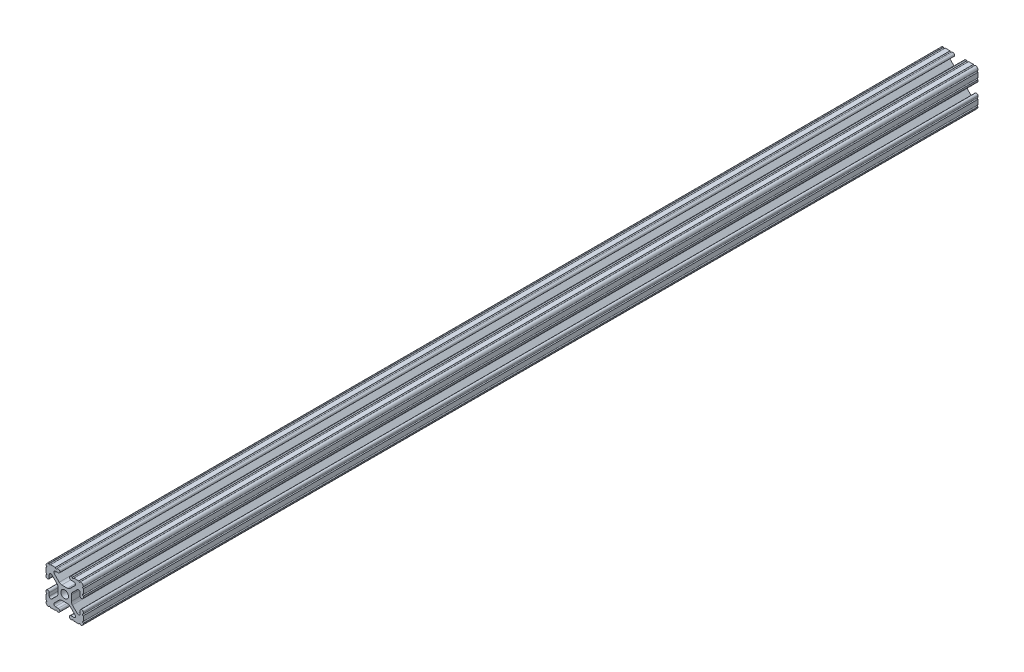
from build123d import *

# Parameters (mm, degrees)
SKETCH3_W                = 25.4
SKETCH3_H                = 25.4
BOSS_EXTRUDE1_DEPTH      = 304.8
BOSS_EXTRUDE1_DEPTH_BACK = 304.8
SKETCH4_R                = 2.6035
CUT_EXTRUDE1_DEPTH       = 610.6
CUT_EXTRUDE2_DEPTH       = 610.6
FILLET1_R                = 2.54
FILLET2_R                = 1.778


with BuildPart() as part:
    # Sketch3 → Boss-Extrude1 (new body, two sides)
    with BuildSketch(Plane.XY) as boss_extrude1_sk:
        Rectangle(SKETCH3_W, SKETCH3_H)
    extrude(amount=BOSS_EXTRUDE1_DEPTH)
    extrude(boss_extrude1_sk.sketch, amount=-BOSS_EXTRUDE1_DEPTH_BACK)

    # Sketch4 → Cut-Extrude1 (cut, through all)
    with BuildSketch(Plane.XY.offset(304.8)):
        with BuildLine():
            Line((3.2512, 12.7), (-3.2512, 12.7))
            Line((-3.2512, 12.7), (-3.2512, 10.4902))
            Line((-3.2512, 10.4902), (-6.348478019, 10.4902))
            ThreePointArc((-6.348478019, 10.4902), (-7.335478831, 9.830707141), (-7.103895736, 8.666460301))
            Line((-7.103895736, 8.666460301), (-2.958635435, 4.5212))
            Line((-2.958635435, 4.5212), (2.958635435, 4.5212))
            Line((2.958635435, 4.5212), (7.103895736, 8.666460301))
            ThreePointArc((7.103895736, 8.666460301), (7.335478831, 9.830707141), (6.348478019, 10.4902))
            Line((6.348478019, 10.4902), (3.2512, 10.4902))
            Line((3.2512, 10.4902), (3.2512, 12.7))
        make_face()
        with BuildLine():
            Line((12.7, -3.2512), (12.7, 3.2512))
            Line((12.7, 3.2512), (10.4902, 3.2512))
            Line((10.4902, 3.2512), (10.4902, 6.348478019))
            ThreePointArc((10.4902, 6.348478019), (9.830707141, 7.335478831), (8.666460301, 7.103895736))
            Line((8.666460301, 7.103895736), (4.5212, 2.958635435))
            Line((4.5212, 2.958635435), (4.5212, -2.958635435))
            Line((4.5212, -2.958635435), (8.666460301, -7.103895736))
            ThreePointArc((8.666460301, -7.103895736), (9.830707141, -7.335478831), (10.4902, -6.348478019))
            Line((10.4902, -6.348478019), (10.4902, -3.2512))
            Line((10.4902, -3.2512), (12.7, -3.2512))
        make_face()
        with BuildLine():
            Line((-3.2512, -10.4902), (-3.2512, -12.7))
            Line((-3.2512, -12.7), (3.2512, -12.7))
            Line((3.2512, -12.7), (3.2512, -10.4902))
            Line((3.2512, -10.4902), (6.348478019, -10.4902))
            ThreePointArc((6.348478019, -10.4902), (7.335478831, -9.830707141), (7.103895736, -8.666460301))
            Line((7.103895736, -8.666460301), (2.958635435, -4.5212))
            Line((2.958635435, -4.5212), (-2.958635435, -4.5212))
            Line((-2.958635435, -4.5212), (-7.103895736, -8.666460301))
            ThreePointArc((-7.103895736, -8.666460301), (-7.335478831, -9.830707141), (-6.348478019, -10.4902))
            Line((-6.348478019, -10.4902), (-3.2512, -10.4902))
        make_face()
        with BuildLine():
            Line((-10.4902, 3.2512), (-12.7, 3.2512))
            Line((-12.7, 3.2512), (-12.7, -3.2512))
            Line((-12.7, -3.2512), (-10.4902, -3.2512))
            Line((-10.4902, -3.2512), (-10.4902, -6.348478019))
            ThreePointArc((-10.4902, -6.348478019), (-9.830707141, -7.335478831), (-8.666460301, -7.103895736))
            Line((-8.666460301, -7.103895736), (-4.5212, -2.958635435))
            Line((-4.5212, -2.958635435), (-4.5212, 2.958635435))
            Line((-4.5212, 2.958635435), (-8.666460301, 7.103895736))
            ThreePointArc((-8.666460301, 7.103895736), (-9.830707141, 7.335478831), (-10.4902, 6.348478019))
            Line((-10.4902, 6.348478019), (-10.4902, 3.2512))
        make_face()
        Circle(SKETCH4_R)
    extrude(amount=-CUT_EXTRUDE1_DEPTH, mode=Mode.SUBTRACT)

    # Sketch5 → Cut-Extrude2 (cut, through all)
    with BuildSketch(Plane.XY.offset(304.8)):
        with BuildLine():
            ThreePointArc((-11.5951, 3.2512), (-12.376382283, 3.574817717), (-12.7, 4.3561))
            Line((-12.7, 4.3561), (-12.7, 3.2512))
            Line((-12.7, 3.2512), (-11.5951, 3.2512))
        make_face()
        with BuildLine():
            ThreePointArc((-10.4902, 4.3561), (-10.813817717, 3.574817717), (-11.5951, 3.2512))
            Line((-11.5951, 3.2512), (-10.4902, 3.2512))
            Line((-10.4902, 3.2512), (-10.4902, 4.3561))
        make_face()
        with BuildLine():
            Line((-12.7, -3.2512), (-12.7, -4.3561))
            ThreePointArc((-12.7, -4.3561), (-12.376382283, -3.574817717), (-11.5951, -3.2512))
            Line((-11.5951, -3.2512), (-12.7, -3.2512))
        make_face()
        with BuildLine():
            Line((-10.4902, -3.2512), (-11.5951, -3.2512))
            ThreePointArc((-11.5951, -3.2512), (-10.813817717, -3.574817717), (-10.4902, -4.3561))
            Line((-10.4902, -4.3561), (-10.4902, -3.2512))
        make_face()
        with BuildLine():
            Line((-3.2512, -11.595100007), (-3.2512, -10.4902))
            Line((-3.2512, -10.4902), (-4.3561, -10.4902))
            ThreePointArc((-4.3561, -10.4902), (-3.574817715, -10.81381772), (-3.2512, -11.595100007))
        make_face()
        with BuildLine():
            Line((-3.2512, -12.7), (-3.2512, -11.595100007))
            ThreePointArc((-3.2512, -11.595100007), (-3.57481772, -12.376382285), (-4.3561, -12.7))
            Line((-4.3561, -12.7), (-3.2512, -12.7))
        make_face()
        with BuildLine():
            Line((3.2512, -10.4902), (3.2512, -11.5951))
            ThreePointArc((3.2512, -11.5951), (3.574817718, -10.813817717), (4.3561, -10.4902))
            Line((4.3561, -10.4902), (3.2512, -10.4902))
        make_face()
        with BuildLine():
            Line((3.2512, -12.7), (4.3561, -12.7))
            ThreePointArc((4.3561, -12.7), (3.574817717, -12.376382282), (3.2512, -11.5951))
            Line((3.2512, -11.5951), (3.2512, -12.7))
        make_face()
        with BuildLine():
            Line((11.5951, -3.2512), (10.4902, -3.2512))
            Line((10.4902, -3.2512), (10.4902, -4.3561))
            ThreePointArc((10.4902, -4.3561), (10.813817717, -3.574817717), (11.5951, -3.2512))
        make_face()
        with BuildLine():
            Line((12.7, -3.2512), (11.5951, -3.2512))
            ThreePointArc((11.5951, -3.2512), (12.376382283, -3.574817717), (12.7, -4.3561))
            Line((12.7, -4.3561), (12.7, -3.2512))
        make_face()
        with BuildLine():
            Line((10.4902, 3.2512), (11.5951, 3.2512))
            ThreePointArc((11.5951, 3.2512), (10.813817717, 3.574817717), (10.4902, 4.3561))
            Line((10.4902, 4.3561), (10.4902, 3.2512))
        make_face()
        with BuildLine():
            Line((12.7, 3.2512), (12.7, 4.3561))
            ThreePointArc((12.7, 4.3561), (12.376382283, 3.574817717), (11.5951, 3.2512))
            Line((11.5951, 3.2512), (12.7, 3.2512))
        make_face()
        with BuildLine():
            Line((3.2512, 12.7), (3.2512, 11.595099996))
            ThreePointArc((3.2512, 11.595099996), (3.574817716, 12.376382281), (4.3561, 12.7))
            Line((4.3561, 12.7), (3.2512, 12.7))
        make_face()
        with BuildLine():
            Line((3.2512, 11.595099996), (3.2512, 10.4902))
            Line((3.2512, 10.4902), (4.3561, 10.4902))
            ThreePointArc((4.3561, 10.4902), (3.574817719, 10.813817716), (3.2512, 11.595099996))
        make_face()
        with BuildLine():
            Line((-3.2512, 12.7), (-4.3561, 12.7))
            ThreePointArc((-4.3561, 12.7), (-3.574817717, 12.376382283), (-3.2512, 11.5951))
            Line((-3.2512, 11.5951), (-3.2512, 12.7))
        make_face()
        with BuildLine():
            Line((-3.2512, 10.4902), (-3.2512, 11.5951))
            ThreePointArc((-3.2512, 11.5951), (-3.574817717, 10.813817717), (-4.3561, 10.4902))
            Line((-4.3561, 10.4902), (-3.2512, 10.4902))
        make_face()
        with BuildLine():
            ThreePointArc((-12.7, 5.23875), (-12.14755, 5.7912), (-12.7, 6.34365))
            Line((-12.7, 6.34365), (-12.7, 5.23875))
        make_face()
        with BuildLine():
            ThreePointArc((-12.7, 9.60755), (-12.14755, 10.16), (-12.7, 10.71245))
            Line((-12.7, 10.71245), (-12.7, 9.60755))
        make_face()
        with BuildLine():
            ThreePointArc((-10.71245, 12.7), (-10.16, 12.14755), (-9.60755, 12.7))
            Line((-9.60755, 12.7), (-10.71245, 12.7))
        make_face()
        with BuildLine():
            ThreePointArc((-6.34365, 12.7), (-5.7912, 12.14755), (-5.23875, 12.7))
            Line((-5.23875, 12.7), (-6.34365, 12.7))
        make_face()
        with BuildLine():
            Line((6.34365, 12.7), (5.23875, 12.7))
            ThreePointArc((5.23875, 12.7), (5.7912, 12.14755), (6.34365, 12.7))
        make_face()
        with BuildLine():
            Line((10.71245, 12.7), (9.60755, 12.7))
            ThreePointArc((9.60755, 12.7), (10.16, 12.14755), (10.71245, 12.7))
        make_face()
        with BuildLine():
            Line((12.7, 10.71245), (12.7, 9.60755))
            ThreePointArc((12.7, 9.60755), (12.14755, 10.16), (12.7, 10.71245))
        make_face()
        with BuildLine():
            Line((12.7, 6.34365), (12.7, 5.23875))
            ThreePointArc((12.7, 5.23875), (12.14755, 5.7912), (12.7, 6.34365))
        make_face()
        with BuildLine():
            Line((-12.7, -6.34365), (-12.7, -5.23875))
            ThreePointArc((-12.7, -5.23875), (-12.14755, -5.7912), (-12.7, -6.34365))
        make_face()
        with BuildLine():
            Line((-12.7, -10.71245), (-12.7, -9.60755))
            ThreePointArc((-12.7, -9.60755), (-12.14755, -10.16), (-12.7, -10.71245))
        make_face()
        with BuildLine():
            Line((-10.71245, -12.7), (-9.60755, -12.7))
            ThreePointArc((-9.60755, -12.7), (-10.16, -12.14755), (-10.71245, -12.7))
        make_face()
        with BuildLine():
            Line((-6.34365, -12.7), (-5.23875, -12.7))
            ThreePointArc((-5.23875, -12.7), (-5.7912, -12.14755), (-6.34365, -12.7))
        make_face()
        with BuildLine():
            Line((12.7, -10.71245), (12.7, -9.60755))
            ThreePointArc((12.7, -9.60755), (12.14755, -10.16), (12.7, -10.71245))
        make_face()
        with BuildLine():
            Line((12.7, -6.34365), (12.7, -5.23875))
            ThreePointArc((12.7, -5.23875), (12.14755, -5.7912), (12.7, -6.34365))
        make_face()
        with BuildLine():
            Line((10.71245, -12.7), (9.60755, -12.7))
            ThreePointArc((9.60755, -12.7), (10.16, -12.14755), (10.71245, -12.7))
        make_face()
        with BuildLine():
            Line((6.34365, -12.7), (5.23875, -12.7))
            ThreePointArc((5.23875, -12.7), (5.7912, -12.14755), (6.34365, -12.7))
        make_face()
    extrude(amount=-CUT_EXTRUDE2_DEPTH, mode=Mode.SUBTRACT)

    # Fillet1
    fillet1_edges = [part.edges().sort_by_distance(p)[0] for p in [
        (2.958635435, 4.5212, 0),
        (-2.958635435, 4.5212, 0),
        (-2.958635435, -4.5212, 0),
        (2.958635435, -4.5212, 0),
        (4.5212, -2.958635435, 0),
        (4.5212, 2.958635435, 0),
        (-4.5212, 2.958635435, 0),
        (-4.5212, -2.958635435, 0),
    ]]
    fillet(fillet1_edges, radius=FILLET1_R)

    # Fillet2
    fillet2_edges = [part.edges().sort_by_distance(p)[0] for p in [
        (-12.7, 12.7, 0),
        (12.7, 12.7, 0),
        (12.7, -12.7, 0),
        (-12.7, -12.7, 0),
    ]]
    fillet(fillet2_edges, radius=FILLET2_R)


solid = part.part
